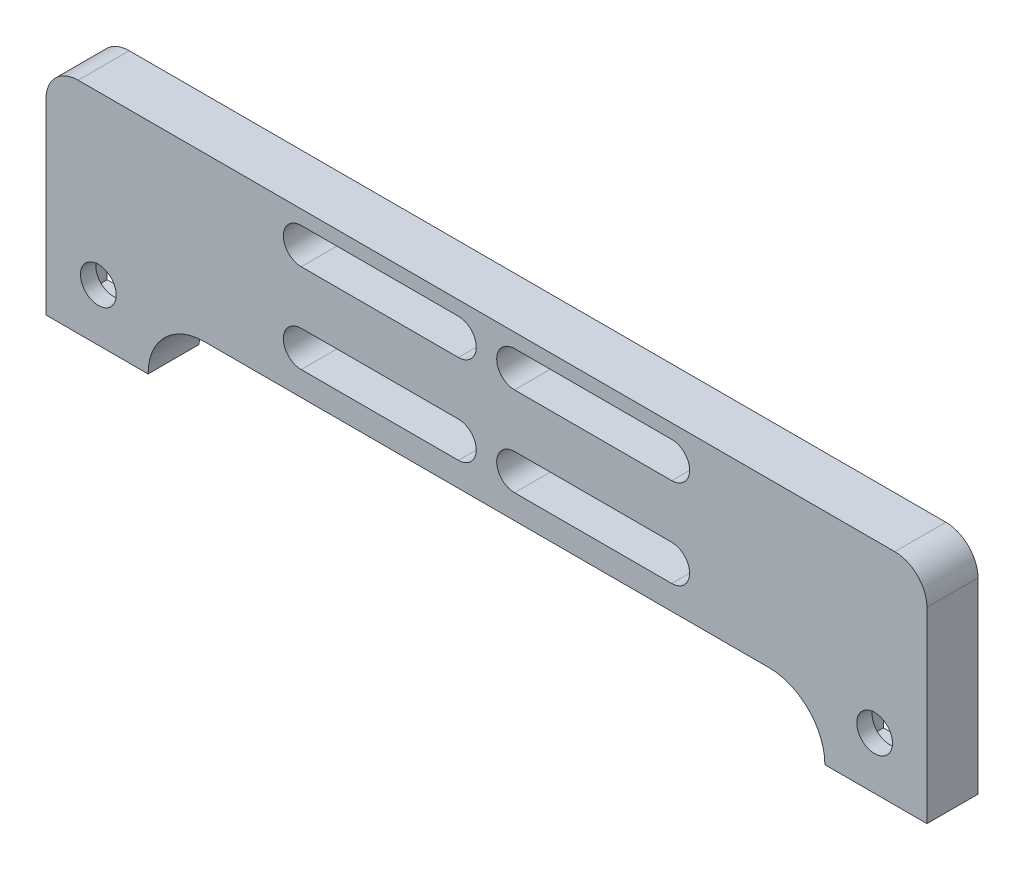
from build123d import *

# Parameters (mm, degrees)
SKETCH1_R               = 4.3
SKETCH1_W               = 12.5
SKETCH1_H               = 12.5
BOSS_EXTRUDE1_DEPTH     = 8
CUT_EXTRUDE1_DEPTH      = 8
SKETCH1_2_R             = 4.3
SKETCH1_2_W             = 12.5
SKETCH1_2_H             = 12.5
BOSS_EXTRUDE2_DEPTH     = 10
CUT_EXTRUDE2_DEPTH      = 3
CUT_EXTRUDE2_DEPTH_BACK = 9
SKETCH3_W               = 12.5
SKETCH3_H               = 12.5
BOSS_EXTRUDE3_DEPTH     = 2
SKETCH4_R               = 4.3
BOSS_EXTRUDE5_DEPTH     = 2
BOSS_EXTRUDE6_DEPTH     = 10
BOSS_EXTRUDE7_DEPTH     = 10
BOSS_EXTRUDE8_DEPTH     = 10
SKETCH8_W               = 18.12209128
SKETCH8_H               = 22.505010211
SKETCH8_W_2             = 16.915072938
SKETCH8_H_2             = 18.768490124
BOSS_EXTRUDE9_DEPTH     = 10
SKETCH12_W              = 16.5
SKETCH12_H              = 16.5
CUT_EXTRUDE6_DEPTH      = 7
SKETCH13_R              = 3.5
CUT_EXTRUDE7_DEPTH      = 7
CUT_EXTRUDE11_DEPTH     = 5


with BuildPart() as part:
    # Sketch1 → Boss-Extrude1 (new body)
    with BuildSketch(Plane.XY):
        with BuildLine():
            Line((-85.345346062, -25.7), (87.254653938, -25.7))
            Line((87.254653938, -25.7), (87.254653938, 0))
            ThreePointArc((87.254653938, 0), (85.409426659, 4.454772721), (80.954653938, 6.3))
            Line((80.954653938, 6.3), (-79.045346062, 6.3))
            ThreePointArc((-79.045346062, 6.3), (-83.500118784, 4.454772721), (-85.345346062, 0))
            Line((-85.345346062, 0), (-85.345346062, -25.7))
        make_face()
        with Locations((-79.045346062, 0)):
            Circle(SKETCH1_R, mode=Mode.SUBTRACT)
        with Locations((80.954653938, 0)):
            Circle(SKETCH1_R, mode=Mode.SUBTRACT)
        with Locations((-77.095346062, -17.45)):
            Rectangle(SKETCH1_W, SKETCH1_H, mode=Mode.SUBTRACT)
        with Locations((79.004653938, -17.45)):
            Rectangle(SKETCH1_W, SKETCH1_H, mode=Mode.SUBTRACT)
    extrude(amount=BOSS_EXTRUDE1_DEPTH)

    # Sketch2 → Cut-Extrude1 (cut)
    with BuildSketch(Plane.XY.offset(8)):
        with BuildLine():
            Line((-35.345346062, 3.5), (37.254653938, 3.5))
            ThreePointArc((37.254653938, 3.5), (40.754653938, 0), (37.254653938, -3.5))
            Line((37.254653938, -3.5), (-35.345346062, -3.5))
            ThreePointArc((-35.345346062, -3.5), (-38.845346062, 0), (-35.345346062, 3.5))
        make_face()
        with BuildLine():
            Line((-35.345346062, -13.95), (37.254653938, -13.95))
            ThreePointArc((37.254653938, -13.95), (40.754653938, -17.45), (37.254653938, -20.95))
            Line((37.254653938, -20.95), (34.643207431, -20.95))
            Line((34.643207431, -20.95), (-35.345346062, -20.95))
            ThreePointArc((-35.345346062, -20.95), (-38.845346062, -17.45), (-35.345346062, -13.95))
        make_face()
    extrude(amount=-CUT_EXTRUDE1_DEPTH, mode=Mode.SUBTRACT)

    # Sketch1_2 → Boss-Extrude2 (add)
    with BuildSketch(Plane.XY):
        with BuildLine():
            Line((-85.345346062, -25.7), (87.254653938, -25.7))
            Line((87.254653938, -25.7), (87.254653938, 0))
            ThreePointArc((87.254653938, 0), (85.409426659, 4.454772721), (80.954653938, 6.3))
            Line((80.954653938, 6.3), (-79.045346062, 6.3))
            ThreePointArc((-79.045346062, 6.3), (-83.500118784, 4.454772721), (-85.345346062, 0))
            Line((-85.345346062, 0), (-85.345346062, -25.7))
        make_face()
        with Locations((-79.045346062, 0)):
            Circle(SKETCH1_2_R, mode=Mode.SUBTRACT)
        with Locations((80.954653938, 0)):
            Circle(SKETCH1_2_R, mode=Mode.SUBTRACT)
        with Locations((-77.095346062, -17.45)):
            Rectangle(SKETCH1_2_W, SKETCH1_2_H, mode=Mode.SUBTRACT)
        with Locations((79.004653938, -17.45)):
            Rectangle(SKETCH1_2_W, SKETCH1_2_H, mode=Mode.SUBTRACT)
    extrude(amount=BOSS_EXTRUDE2_DEPTH)

    # Sketch2_2 → Cut-Extrude2 (cut, two sides)
    with BuildSketch(Plane.XY.offset(8)) as cut_extrude2_sk:
        with BuildLine():
            Line((-35.345346062, 3.5), (37.254653938, 3.5))
            ThreePointArc((37.254653938, 3.5), (40.754653938, 0), (37.254653938, -3.5))
            Line((37.254653938, -3.5), (-35.345346062, -3.5))
            ThreePointArc((-35.345346062, -3.5), (-38.845346062, 0), (-35.345346062, 3.5))
        make_face()
        with BuildLine():
            Line((-35.345346062, -13.95), (37.254653938, -13.95))
            ThreePointArc((37.254653938, -13.95), (40.754653938, -17.45), (37.254653938, -20.95))
            Line((37.254653938, -20.95), (34.643207431, -20.95))
            Line((34.643207431, -20.95), (-35.345346062, -20.95))
            ThreePointArc((-35.345346062, -20.95), (-38.845346062, -17.45), (-35.345346062, -13.95))
        make_face()
    extrude(amount=CUT_EXTRUDE2_DEPTH, mode=Mode.SUBTRACT)
    extrude(cut_extrude2_sk.sketch, amount=-CUT_EXTRUDE2_DEPTH_BACK, mode=Mode.SUBTRACT)

    # Sketch3 → Boss-Extrude3 (add)
    with BuildSketch(Plane.XY.offset(10)):
        with Locations((-77.095346062, -17.45)):
            Rectangle(SKETCH3_W, SKETCH3_H)
        with Locations((79.004653938, -17.45)):
            Rectangle(SKETCH3_W, SKETCH3_H)
    extrude(amount=-BOSS_EXTRUDE3_DEPTH)

    # Sketch4 → Boss-Extrude5 (add)
    with BuildSketch(Plane.XY.offset(10)):
        with Locations((-79.045346062, 0)):
            Circle(SKETCH4_R)
        with Locations((80.954653938, 0)):
            Circle(SKETCH4_R)
    extrude(amount=-BOSS_EXTRUDE5_DEPTH)

    # Sketch5 → Boss-Extrude6 (add)
    with BuildSketch(Plane.XY.offset(10)):
        with BuildLine():
            Line((-4.545346062, 3.5), (6.454653938, 3.5))
            ThreePointArc((6.454653938, 3.5), (2.954653938, 0), (6.454653938, -3.5))
            Line((6.454653938, -3.5), (-4.545346062, -3.5))
            ThreePointArc((-4.545346062, -3.5), (-1.045346062, 0), (-4.545346062, 3.5))
        make_face()
    extrude(amount=-BOSS_EXTRUDE6_DEPTH)

    # Sketch6 → Boss-Extrude7 (add)
    with BuildSketch(Plane.XY.offset(10)):
        with BuildLine():
            Line((-4.545346062, -13.95), (6.454653938, -13.95))
            ThreePointArc((6.454653938, -13.95), (2.954653938, -17.45), (6.454653938, -20.95))
            Line((6.454653938, -20.95), (-4.545346062, -20.95))
            ThreePointArc((-4.545346062, -20.95), (-1.045346062, -17.45), (-4.545346062, -13.95))
        make_face()
    extrude(amount=-BOSS_EXTRUDE7_DEPTH)

    # Sketch7 → Boss-Extrude8 (add)
    with BuildSketch(Plane.XY.offset(10)):
        with BuildLine():
            Line((-85.345346062, -25.7), (-85.345346062, -36.7))
            Line((-85.345346062, -36.7), (-65.345346062, -36.7))
            ThreePointArc((-65.345346062, -36.7), (-62.123520655, -28.921825407), (-54.345346062, -25.7))
            Line((-54.345346062, -25.7), (-85.345346062, -25.7))
        make_face()
        with BuildLine():
            Line((87.254653938, -25.7), (87.254653938, -36.7))
            Line((87.254653938, -36.7), (67.254653938, -36.7))
            ThreePointArc((67.254653938, -36.7), (64.032828531, -28.921825407), (56.254653938, -25.7))
            Line((56.254653938, -25.7), (87.254653938, -25.7))
        make_face()
    extrude(amount=-BOSS_EXTRUDE8_DEPTH)

    # Sketch8 → Boss-Extrude9 (add)
    with BuildSketch(Plane(origin=(0, 0, 0), x_dir=(-1, 0, 0), z_dir=(0, 0, -1))):
        with Locations((-77.426938653, -19.427407937)):
            Rectangle(SKETCH8_W, SKETCH8_H)
        with Locations((75.829945686, -18.535840795)):
            Rectangle(SKETCH8_W_2, SKETCH8_H_2)
    extrude(amount=-BOSS_EXTRUDE9_DEPTH)

    # Sketch12 → Cut-Extrude6 (cut)
    with BuildSketch(Plane(origin=(0, 0, 0), x_dir=(-1, 0, 0), z_dir=(0, 0, -1))):
        with Locations((-77.004653938, -26.45)):
            Rectangle(SKETCH12_W, SKETCH12_H)
        with Locations((75.095346062, -26.45)):
            Rectangle(SKETCH12_W, SKETCH12_H)
    extrude(amount=-CUT_EXTRUDE6_DEPTH, mode=Mode.SUBTRACT)

    # Sketch13 → Cut-Extrude7 (cut)
    with BuildSketch(Plane(origin=(0, 0, 7), x_dir=(-1, 0, 0), z_dir=(0, 0, -1))):
        with Locations((75.095346062, -26.45)):
            Circle(SKETCH13_R)
        with Locations((-77.004653938, -26.45)):
            Circle(SKETCH13_R)
    extrude(amount=-CUT_EXTRUDE7_DEPTH, mode=Mode.SUBTRACT)

    # Sketch14 → Cut-Extrude11 (cut)
    with BuildSketch(Plane(origin=(0, 0, 0), x_dir=(-1, 0, 0), z_dir=(0, 0, -1))):
        with BuildLine():
            Line((-75.954653938, -5.5), (-5.954653938, -5.5))
            ThreePointArc((-5.954653938, -5.5), (-2.729653938, -8.725), (-5.954653938, -11.95))
            Line((-5.954653938, -11.95), (-75.954653938, -11.95))
            ThreePointArc((-75.954653938, -11.95), (-79.179653938, -8.725), (-75.954653938, -5.5))
        make_face()
        with BuildLine():
            Line((4.045346062, -5.5), (6.774875553, -5.5))
            Line((6.774875553, -5.5), (74.045346062, -5.5))
            ThreePointArc((74.045346062, -5.5), (77.270346062, -8.725), (74.045346062, -11.95))
            Line((74.045346062, -11.95), (4.045346062, -11.95))
            ThreePointArc((4.045346062, -11.95), (0.820346062, -8.725), (4.045346062, -5.5))
        make_face()
    extrude(amount=-CUT_EXTRUDE11_DEPTH, mode=Mode.SUBTRACT)


solid = part.part
